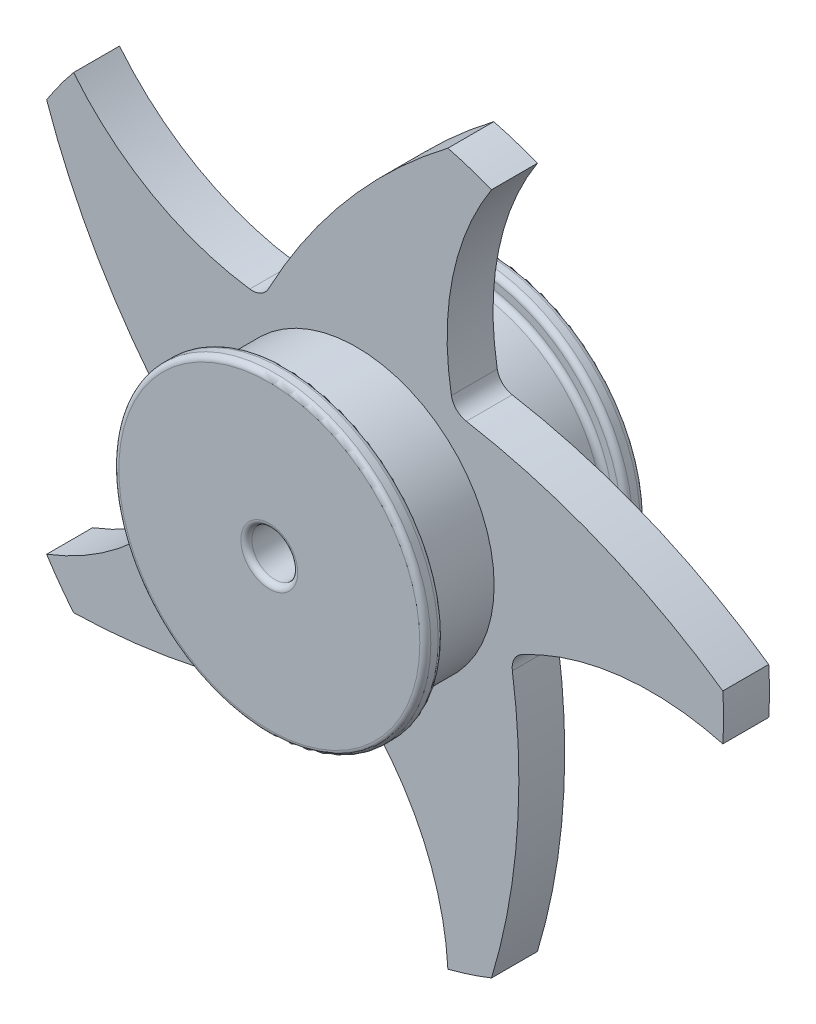
from build123d import *

# Parameters (mm, degrees)
SKETCH1_R            = 75
SKETCH1_R_2          = 12.5
BOSS_EXTRUDE1_DEPTH  = 60
SKETCH2_R            = 85
SKETCH2_R_2          = 75
BOSS_EXTRUDE2_DEPTH  = 10
FILLET1_R            = 3
FILLET1_OF_MIRROR2_R = 3
BOSS_EXTRUDE3_DEPTH  = 12.5
CIRPATTERN1_COUNT    = 5
FILLET2_R            = 10


with BuildPart() as part:
    # Sketch1 → Boss-Extrude1 (new body, symmetric)
    with BuildSketch(Plane.XY):
        Circle(SKETCH1_R)
        Circle(SKETCH1_R_2, mode=Mode.SUBTRACT)
    extrude(amount=BOSS_EXTRUDE1_DEPTH, both=True)

    # Sketch2 → Boss-Extrude2 (add)
    with BuildSketch(Plane.XY.offset(60)):
        Circle(SKETCH2_R)
        Circle(SKETCH2_R_2, mode=Mode.SUBTRACT)
    boss_extrude2 = extrude(amount=-BOSS_EXTRUDE2_DEPTH)

    # Fillet1
    fillet1_edges = [part.edges().sort_by_distance(p)[0] for p in [
        (-85, 0, 50),
        (-85, 0, 60),
        (-12.5, 0, -60),
        (-12.5, 0, 60),
        (-75, 0, 50),
    ]]
    fillet(fillet1_edges, radius=FILLET1_R)

    # Mirror2: Boss-Extrude2 across plane
    add(boss_extrude2.mirror(Plane.XY))

    # Fillet1 of Mirror2
    fillet1_of_mirror2_edges = [part.edges().sort_by_distance(p)[0] for p in [
        (-85, 0, -50),
        (-85, 0, -60),
        (-12.5, 0, 60),
        (-12.5, 0, -60),
        (-75, 0, -50),
    ]]
    fillet(fillet1_of_mirror2_edges, radius=FILLET1_OF_MIRROR2_R)

    # Sketch3 → Boss-Extrude3 (add, symmetric)
    with BuildSketch(Plane.XY):
        with BuildLine():
            ThreePointArc((199.608992783, -12.5), (200, 0), (199.608992783, 12.5))
            ThreePointArc((199.608992783, 12.5), (104.582503317, 59.009730397), (0, 75))
            ThreePointArc((0, 75), (69.136631409, 29.071054289), (53.596660401, -52.463301401))
            ThreePointArc((53.596660401, -52.463301401), (121.191649103, -12.711045709), (199.608992783, -12.5))
        make_face()
    boss_extrude3 = extrude(amount=BOSS_EXTRUDE3_DEPTH, both=True)

    # CirPattern1: Boss-Extrude3 ×5 about axis
    cirpattern1_axis = Axis((0, 0, 0), (0, 0, 1))
    for i in range(1, CIRPATTERN1_COUNT):
        add(boss_extrude3.rotate(cirpattern1_axis, i * 360 / CIRPATTERN1_COUNT))

    # Fillet2
    fillet2_edges = [part.edges().sort_by_distance(p)[0] for p in [
        (83.889035282, -28.602309627, 0),
        (53.125550496, 70.944613897, 0),
        (-1.279275408, -88.621813404, 0),
        (-84.679670965, -26.168983201, 0),
        (-51.055639404, 72.448492335, 0),
    ]]
    fillet(fillet2_edges, radius=FILLET2_R)


solid = part.part
